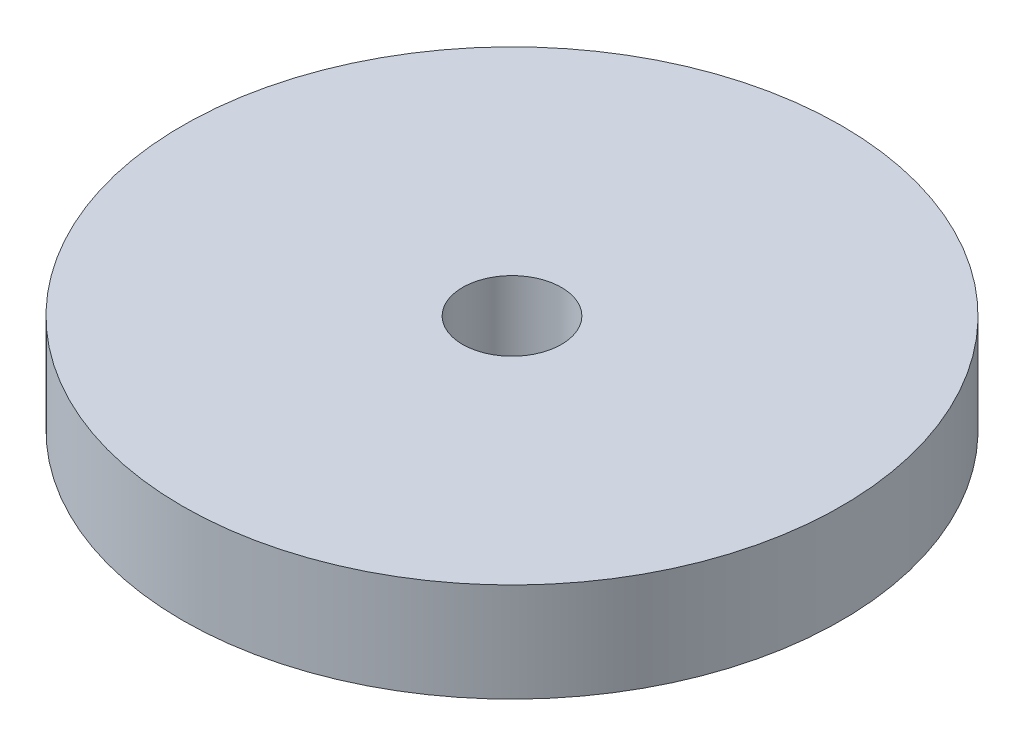
from build123d import *

# Parameters (mm, degrees)
SKETCH1_R           = 10
SKETCH1_R_2         = 1.5
BOSS_EXTRUDE1_DEPTH = 3


with BuildPart() as part:
    # Sketch1 → Boss-Extrude1 (new body)
    with BuildSketch(Plane(origin=(0, 0, 0), x_dir=(1, 0, 0), z_dir=(0, 1, 0))):
        Circle(SKETCH1_R)
        Circle(SKETCH1_R_2, mode=Mode.SUBTRACT)
    extrude(amount=BOSS_EXTRUDE1_DEPTH)


solid = part.part
